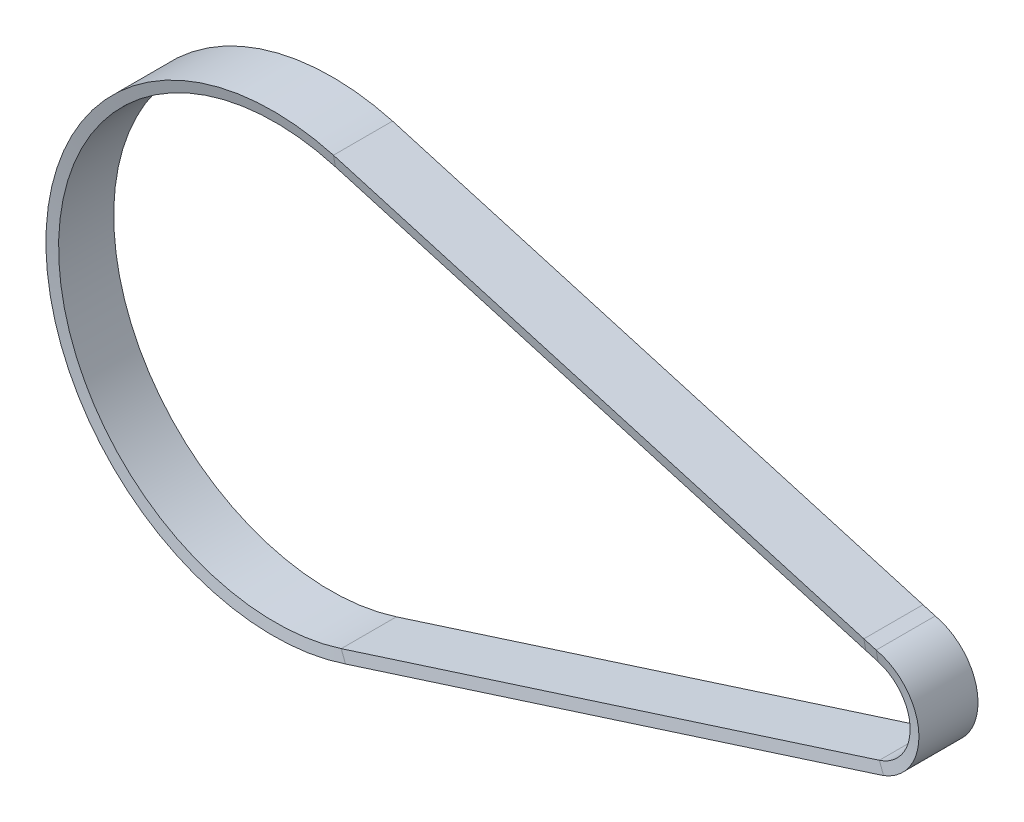
from build123d import *


with BuildPart() as part:
    # Sweep1: sweep along a path in Sketch1
    with BuildLine(Plane.XY) as sweep1_path:
        Line((-269.367760248, 101.444614144), (6.259634921, 21.611732246))
        ThreePointArc((6.259634921, 21.611732246), (22.49778149, 0.315955763), (6.864070948, -21.427424717))
        Line((6.864070948, -21.427424717), (-266.412739672, -108.969042119))
        ThreePointArc((-266.412739672, -108.969042119), (-409.959573811, -5.757416118), (-269.367760248, 101.444614144))
    # Sketch2 → Sweep1 (sweep)
    with BuildSketch(Plane(origin=(0, 0, 0), x_dir=(0, 0, -1), z_dir=(1, 0, 0))):
        Polygon((-15, 29.06477661), (15, 29.06477661), (14, 23.42477661), (-14, 23.42477661), align=None)
    sweep(path=sweep1_path.line)


solid = part.part
